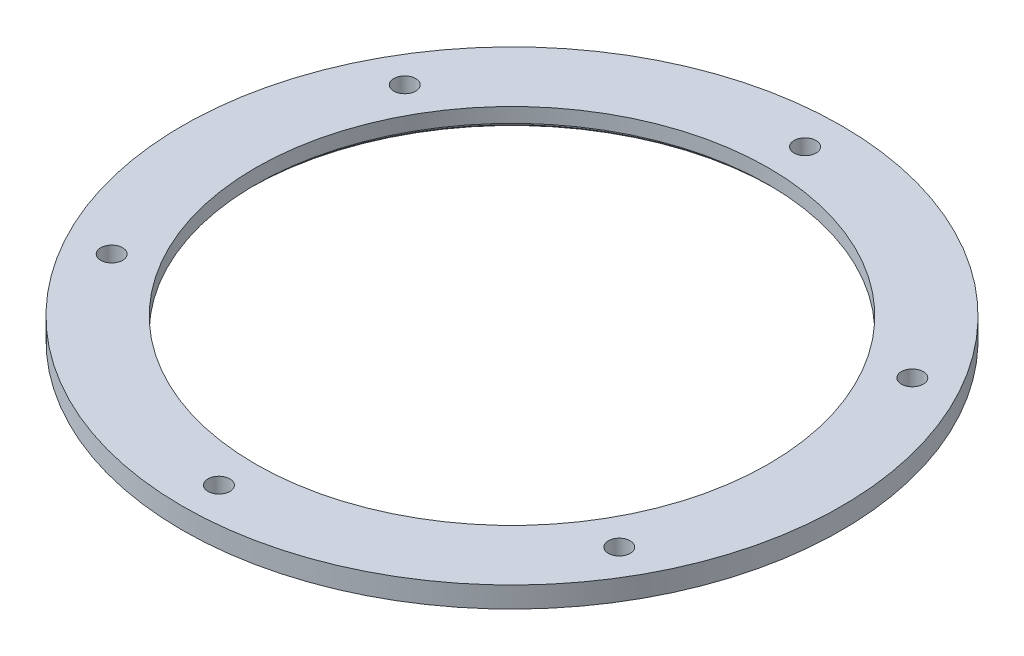
from build123d import *

# Parameters (mm, degrees)
SKETCH1_R           = 158
SKETCH1_R_2         = 123
SKETCH1_R_3         = 5.25
BOSS_EXTRUDE1_DEPTH = 10
SKETCH2_R           = 125
CUT_EXTRUDE1_DEPTH  = 3
CHAMFER1_SIZE       = 1


with BuildPart() as part:
    # Sketch1 → Boss-Extrude1 (new body)
    with BuildSketch(Plane(origin=(0, 0, 0), x_dir=(1, 0, 0), z_dir=(0, 1, 0))):
        Circle(SKETCH1_R)
        Circle(SKETCH1_R_2, mode=Mode.SUBTRACT)
        with Locations((0, 140.5)):
            Circle(SKETCH1_R_3, mode=Mode.SUBTRACT)
        with Locations((121.676569232, 70.25)):
            Circle(SKETCH1_R_3, mode=Mode.SUBTRACT)
        with Locations((121.676569232, -70.25)):
            Circle(SKETCH1_R_3, mode=Mode.SUBTRACT)
        with Locations((0, -140.5)):
            Circle(SKETCH1_R_3, mode=Mode.SUBTRACT)
        with Locations((-121.676569232, -70.25)):
            Circle(SKETCH1_R_3, mode=Mode.SUBTRACT)
        with Locations((-121.676569232, 70.25)):
            Circle(SKETCH1_R_3, mode=Mode.SUBTRACT)
    extrude(amount=BOSS_EXTRUDE1_DEPTH)

    # Sketch2 → Cut-Extrude1 (cut)
    with BuildSketch(Plane.XZ):
        Circle(SKETCH2_R)
    extrude(amount=-CUT_EXTRUDE1_DEPTH, mode=Mode.SUBTRACT)

    # Chamfer1
    chamfer1_edges = [part.edges().sort_by_distance(p)[0] for p in [
        (-125, 0, 0),
    ]]
    chamfer(chamfer1_edges, length=CHAMFER1_SIZE)


solid = part.part
